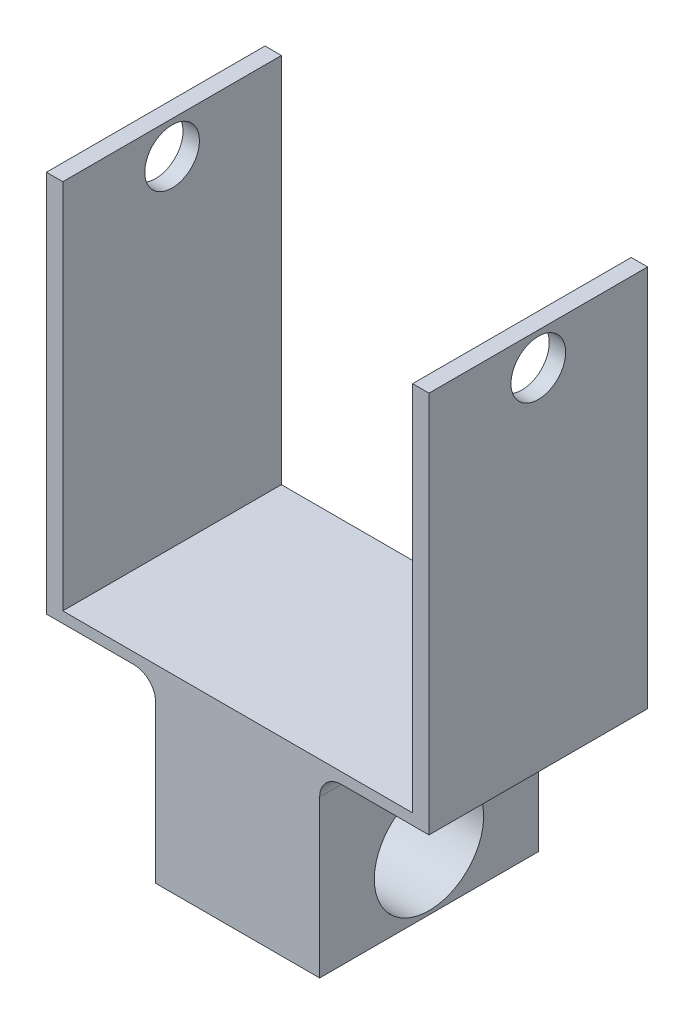
from build123d import *

# Parameters (mm, degrees)
SKETCH1_W               = 35
SKETCH1_H               = 20
BOSS_EXTRUDE1_DEPTH     = 40
SKETCH2_W               = 15
SKETCH2_H               = 20
BOSS_EXTRUDE2_DEPTH     = 16
SKETCH3_R               = 5
CUT_EXTRUDE1_DEPTH      = 26
FILLET3_R               = 3
SKETCH4_W               = 32
SKETCH4_H               = 34
CUT_EXTRUDE2_DEPTH      = 21
SKETCH5_R               = 2.5
CUT_EXTRUDE3_DEPTH      = 36
SKETCH7_W               = 10
SKETCH7_H               = 5
CUT_EXTRUDE4_DEPTH      = 21
FILLET5_R               = 2
SKETCH8_W               = 20
SKETCH8_H               = 4.66822317
CUT_EXTRUDE5_DEPTH      = 18.5
CUT_EXTRUDE5_DEPTH_BACK = 18.5


with BuildPart() as part:
    # Sketch1 → Boss-Extrude1 (new body)
    with BuildSketch(Plane(origin=(0, 0, 0), x_dir=(1, 0, 0), z_dir=(0, 1, 0))):
        with Locations((0, 10)):
            Rectangle(SKETCH1_W, SKETCH1_H)
    extrude(amount=BOSS_EXTRUDE1_DEPTH)

    # Sketch2 → Boss-Extrude2 (add)
    with BuildSketch(Plane.XZ):
        with Locations((0, -10)):
            Rectangle(SKETCH2_W, SKETCH2_H)
    extrude(amount=BOSS_EXTRUDE2_DEPTH)

    # Sketch3 → Cut-Extrude1 (cut, through all)
    with BuildSketch(Plane.ZY.offset(7.5)):
        with Locations((-10, -6)):
            Circle(SKETCH3_R)
    extrude(amount=-CUT_EXTRUDE1_DEPTH, mode=Mode.SUBTRACT)

    # Fillet3
    fillet3_edges = [part.edges().sort_by_distance(p)[0] for p in [
        (7.5, -16, -10),
        (-7.5, -16, -10),
    ]]
    fillet(fillet3_edges, radius=FILLET3_R)

    # Sketch4 → Cut-Extrude2 (cut, through all)
    with BuildSketch(Plane.XY):
        with Locations((0, 23)):
            Rectangle(SKETCH4_W, SKETCH4_H)
    extrude(amount=-CUT_EXTRUDE2_DEPTH, mode=Mode.SUBTRACT)

    # Sketch5 → Cut-Extrude3 (cut, through all)
    with BuildSketch(Plane.ZY.offset(17.5)):
        with Locations((-10, 37)):
            Circle(SKETCH5_R)
    extrude(amount=-CUT_EXTRUDE3_DEPTH, mode=Mode.SUBTRACT)

    # Sketch7 → Cut-Extrude4 (cut, through all)
    with BuildSketch(Plane(origin=(0, 0, -20), x_dir=(-1, 0, 0), z_dir=(0, 0, -1))):
        with Locations((12.5, 2.5)):
            Rectangle(SKETCH7_W, SKETCH7_H)
        with Locations((-12.5, 2.5)):
            Rectangle(SKETCH7_W, SKETCH7_H)
    extrude(amount=-CUT_EXTRUDE4_DEPTH, mode=Mode.SUBTRACT)

    # Fillet5
    fillet5_edges = [part.edges().sort_by_distance(p)[0] for p in [
        (7.5, 5, -10),
        (-7.5, 5, -10),
    ]]
    fillet(fillet5_edges, radius=FILLET5_R)

    # Sketch8 → Cut-Extrude5 (cut, two sides)
    with BuildSketch(Plane(origin=(0, 0, 0), x_dir=(0, 0, -1), z_dir=(1, 0, 0))) as cut_extrude5_sk:
        with Locations((10, -13.665888415)):
            Rectangle(SKETCH8_W, SKETCH8_H)
    extrude(amount=CUT_EXTRUDE5_DEPTH, mode=Mode.SUBTRACT)
    extrude(cut_extrude5_sk.sketch, amount=-CUT_EXTRUDE5_DEPTH_BACK, mode=Mode.SUBTRACT)


solid = part.part
